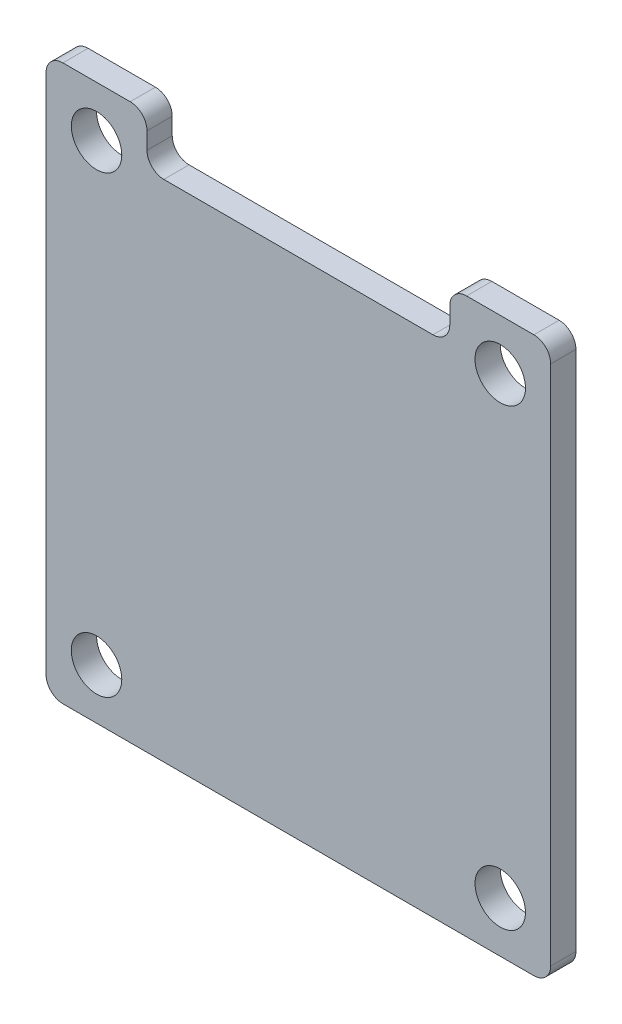
from build123d import *

# Parameters (mm, degrees)
SKETCH_1_R      = 1.5
SKETCH_1_R_2    = 1.499580178
EXTRUDE_1_DEPTH = 1.5
FILLET_2_R      = 1


with BuildPart() as part:
    # ｽｹｯﾁ1 → ﾎﾞｽ - 押し出し1 (new body)
    with BuildSketch(Plane.XY):
        Polygon((-15, 18), (-15, -15), (15, -15), (15, 18), (9, 18), (9, 15), (-9, 15), (-9, 18), align=None)
        with Locations((-12, 15)):
            Circle(SKETCH_1_R, mode=Mode.SUBTRACT)
        with Locations((12, 15)):
            Circle(SKETCH_1_R, mode=Mode.SUBTRACT)
        with Locations((-12, -12)):
            Circle(SKETCH_1_R, mode=Mode.SUBTRACT)
        with Locations((12, -12)):
            Circle(SKETCH_1_R_2, mode=Mode.SUBTRACT)
    extrude(amount=EXTRUDE_1_DEPTH)

    # ﾌｨﾚｯﾄ2
    fillet_2_edges = [part.edges().sort_by_distance(p)[0] for p in [
        (9, 15, 0.75),
        (9, 18, 0.75),
        (15, 18, 0.75),
        (15, -15, 0.75),
        (-15, -15, 0.75),
        (-15, 18, 0.75),
        (-9, 18, 0.75),
        (-9, 15, 0.75),
    ]]
    fillet(fillet_2_edges, radius=FILLET_2_R)


solid = part.part
